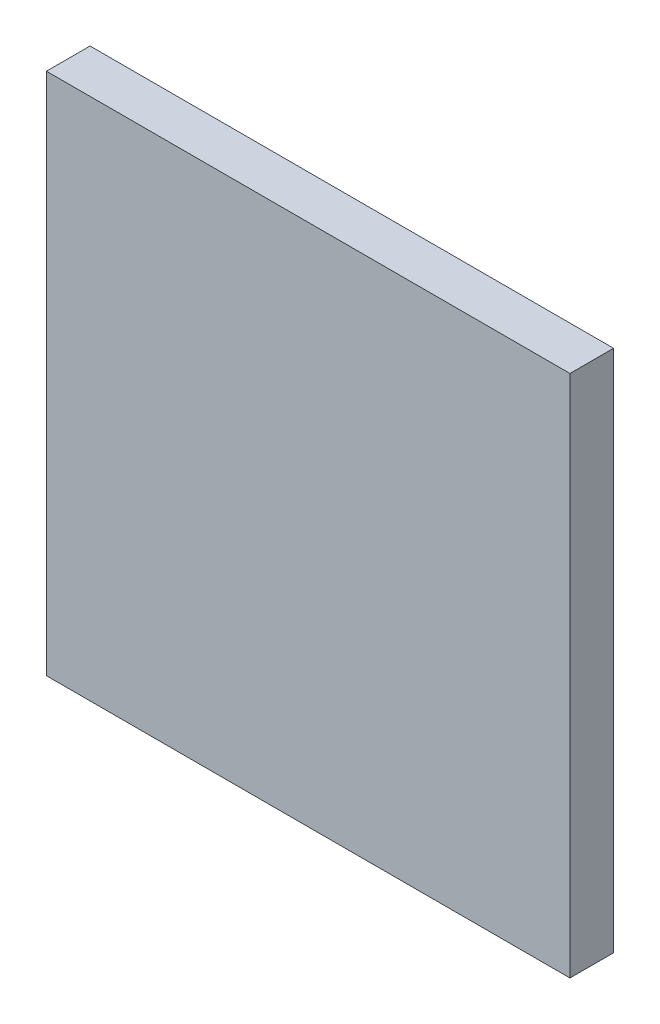
from build123d import *

# Parameters (mm, degrees)
SKETCH1_W           = 76.2
SKETCH1_H           = 76.2
BOSS_EXTRUDE1_DEPTH = 6.35


with BuildPart() as part:
    # Sketch1 → Boss-Extrude1 (new body)
    with BuildSketch(Plane.XY):
        with Locations((38.1, 38.1)):
            Rectangle(SKETCH1_W, SKETCH1_H)
    extrude(amount=BOSS_EXTRUDE1_DEPTH)


solid = part.part
